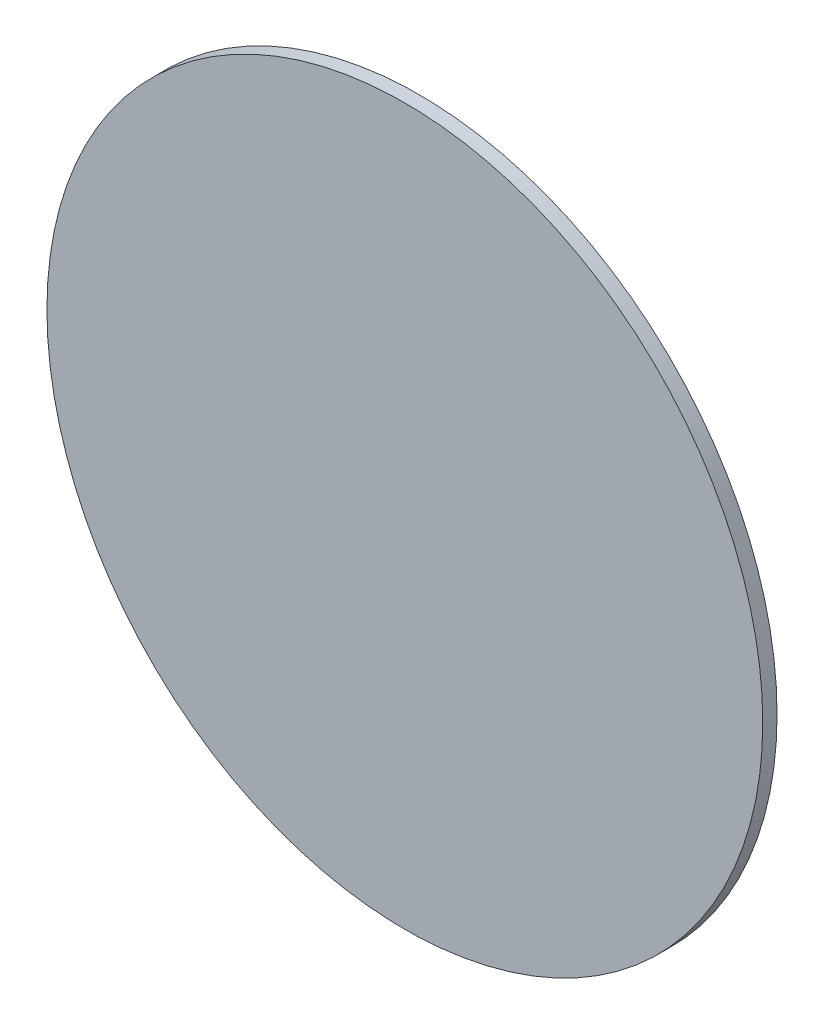
from build123d import *

# Parameters (mm, degrees)
SKETCH1_R           = 6.35
BOSS_EXTRUDE1_DEPTH = 0.254


with BuildPart() as part:
    # Sketch1 → Boss-Extrude1 (new body)
    with BuildSketch(Plane.XY):
        Circle(SKETCH1_R)
    extrude(amount=BOSS_EXTRUDE1_DEPTH)


solid = part.part
